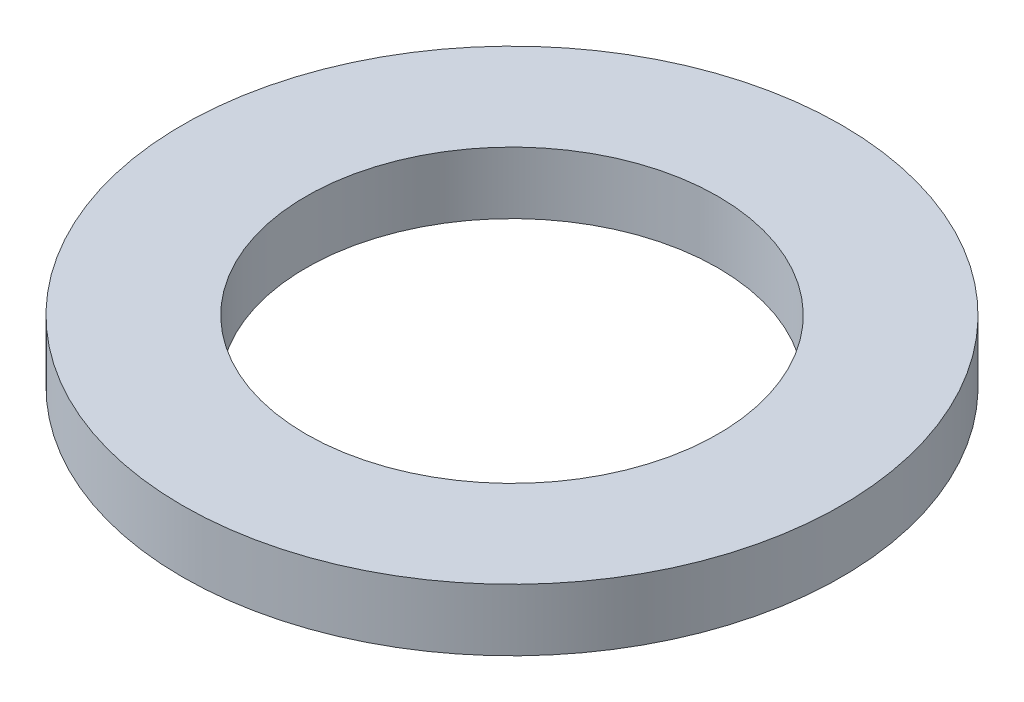
from build123d import *

# Parameters (mm, degrees)
SKETCH1_R           = 12.7
SKETCH1_R_2         = 7.9375
BOSS_EXTRUDE1_DEPTH = 2.3876


with BuildPart() as part:
    # Sketch1 → Boss-Extrude1 (new body)
    with BuildSketch(Plane(origin=(0, 0, 0), x_dir=(1, 0, 0), z_dir=(0, 1, 0))):
        Circle(SKETCH1_R)
        Circle(SKETCH1_R_2, mode=Mode.SUBTRACT)
    extrude(amount=BOSS_EXTRUDE1_DEPTH)


solid = part.part
